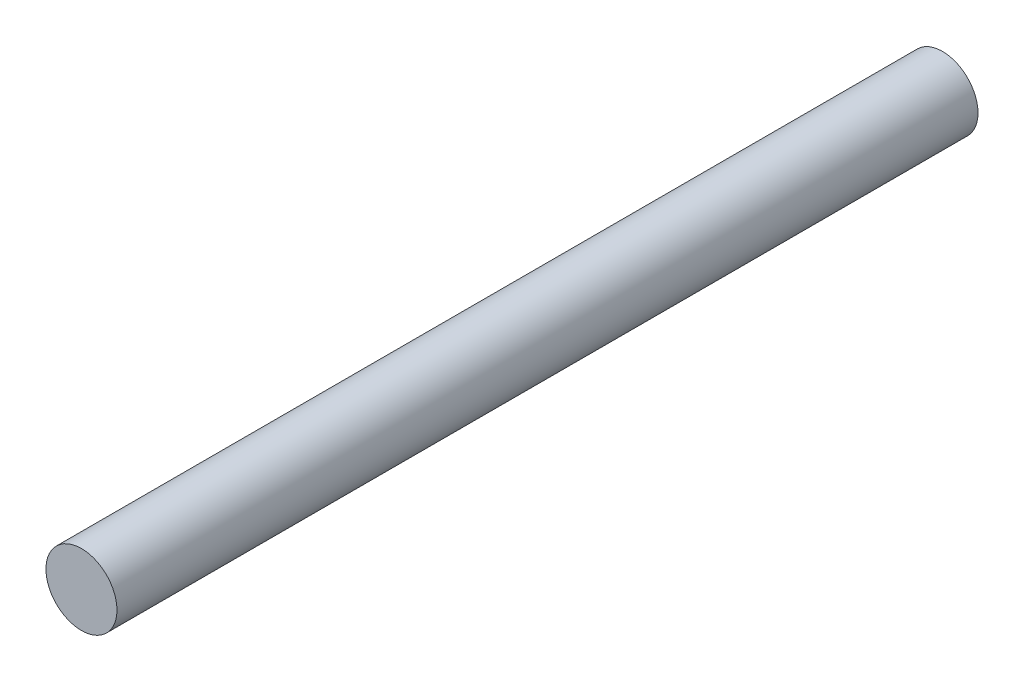
from build123d import *

# Parameters (mm, degrees)
SKICA1_R                = 1.65
P_IDAT_VYSUNUT_M1_DEPTH = 40


with BuildPart() as part:
    # Skica1 → Přidat vysunutím1 (new body)
    with BuildSketch(Plane.XY):
        Circle(SKICA1_R)
    extrude(amount=P_IDAT_VYSUNUT_M1_DEPTH)


solid = part.part
